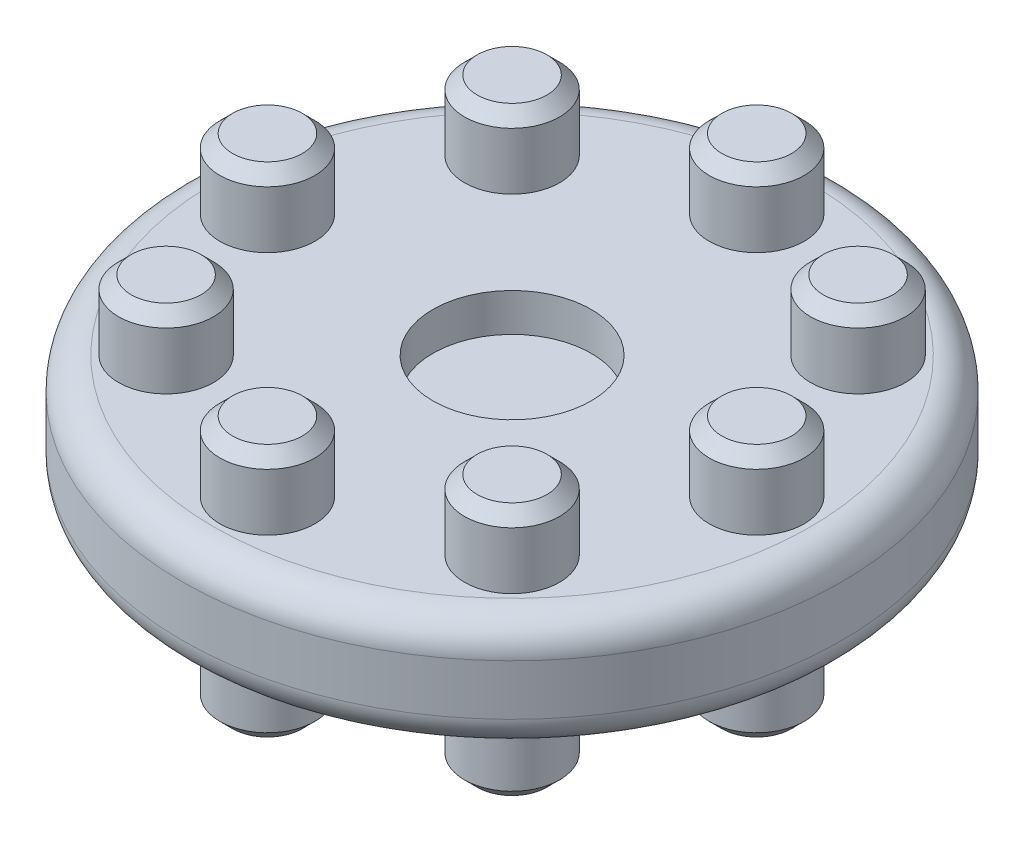
from build123d import *

# Parameters (mm, degrees)
SKETCH1_R           = 26
BOSS_EXTRUDE1_DEPTH = 9
SKETCH2_R           = 6.1
CUT_EXTRUDE2_DEPTH  = 3
CUT_EXTRUDE5_START  = 9
SKETCH1_9_R         = 6.25
CUT_EXTRUDE5_DEPTH  = 3
SKETCH1_11_R        = 3.75
BOSS_EXTRUDE3_DEPTH = 5.5
BOSS_EXTRUDE4_START = 9
SKETCH1_12_R        = 3.75
BOSS_EXTRUDE4_DEPTH = 5.5
CHAMFER1_SIZE       = 1
FILLET1_R           = 2.5


with BuildPart() as part:
    # Sketch1 → Boss-Extrude1 (new body)
    with BuildSketch(Plane(origin=(0, 0, 0), x_dir=(1, 0, 0), z_dir=(0, 1, 0))):
        Circle(SKETCH1_R)
    extrude(amount=BOSS_EXTRUDE1_DEPTH)

    # Sketch2 → Cut-Extrude2 (cut)
    with BuildSketch(Plane.XZ):
        Circle(SKETCH2_R)
    extrude(amount=-CUT_EXTRUDE2_DEPTH, mode=Mode.SUBTRACT)

    # Sketch1_9 → Cut-Extrude5 (cut)
    with BuildSketch(Plane(origin=(0, 0, 0), x_dir=(1, 0, 0), z_dir=(0, 1, 0)).offset(CUT_EXTRUDE5_START)):
        Circle(SKETCH1_9_R)
    extrude(amount=-CUT_EXTRUDE5_DEPTH, mode=Mode.SUBTRACT)

    # Sketch1_11 → Boss-Extrude3 (add)
    with BuildSketch(Plane(origin=(0, 0, 0), x_dir=(1, 0, 0), z_dir=(0, 1, 0))):
        with Locations((-13.647160877, 13.647160877)):
            Circle(SKETCH1_11_R)
        with Locations((0, 19.3)):
            Circle(SKETCH1_11_R)
        with Locations((13.647160877, 13.647160877)):
            Circle(SKETCH1_11_R)
        with Locations((19.3, 0)):
            Circle(SKETCH1_11_R)
        with Locations((13.647160877, -13.647160877)):
            Circle(SKETCH1_11_R)
        with Locations((0, -19.3)):
            Circle(SKETCH1_11_R)
        with Locations((-13.647160877, -13.647160877)):
            Circle(SKETCH1_11_R)
        with Locations((-19.3, 0)):
            Circle(SKETCH1_11_R)
    extrude(amount=-BOSS_EXTRUDE3_DEPTH)

    # Sketch1_12 → Boss-Extrude4 (add)
    with BuildSketch(Plane(origin=(0, 0, 0), x_dir=(1, 0, 0), z_dir=(0, 1, 0)).offset(BOSS_EXTRUDE4_START)):
        with Locations((-13.647160877, 13.647160877)):
            Circle(SKETCH1_12_R)
        with Locations((0, 19.3)):
            Circle(SKETCH1_12_R)
        with Locations((13.647160877, 13.647160877)):
            Circle(SKETCH1_12_R)
        with Locations((19.3, 0)):
            Circle(SKETCH1_12_R)
        with Locations((13.647160877, -13.647160877)):
            Circle(SKETCH1_12_R)
        with Locations((0, -19.3)):
            Circle(SKETCH1_12_R)
        with Locations((-13.647160877, -13.647160877)):
            Circle(SKETCH1_12_R)
        with Locations((-19.3, 0)):
            Circle(SKETCH1_12_R)
    extrude(amount=BOSS_EXTRUDE4_DEPTH)

    # Chamfer1
    chamfer1_edges = [part.edges().sort_by_distance(p)[0] for p in [
        (-17.397160877, -5.5, -13.647160877),
        (-3.75, -5.5, -19.3),
        (9.897160877, -5.5, -13.647160877),
        (15.55, -5.5, 0),
        (9.897160877, -5.5, 13.647160877),
        (-3.75, -5.5, 19.3),
        (-17.397160877, -5.5, 13.647160877),
        (-23.05, -5.5, 0),
        (15.55, 14.5, 0),
        (9.897160877, 14.5, -13.647160877),
        (-3.75, 14.5, -19.3),
        (-17.397160877, 14.5, -13.647160877),
        (-3.75, 14.5, 19.3),
        (9.897160877, 14.5, 13.647160877),
        (-23.05, 14.5, 0),
        (-17.397160877, 14.5, 13.647160877),
    ]]
    chamfer(chamfer1_edges, length=CHAMFER1_SIZE)

    # Fillet1
    fillet1_edges = [part.edges().sort_by_distance(p)[0] for p in [
        (-26, 0, 0),
        (-26, 9, 0),
    ]]
    fillet(fillet1_edges, radius=FILLET1_R)


solid = part.part
